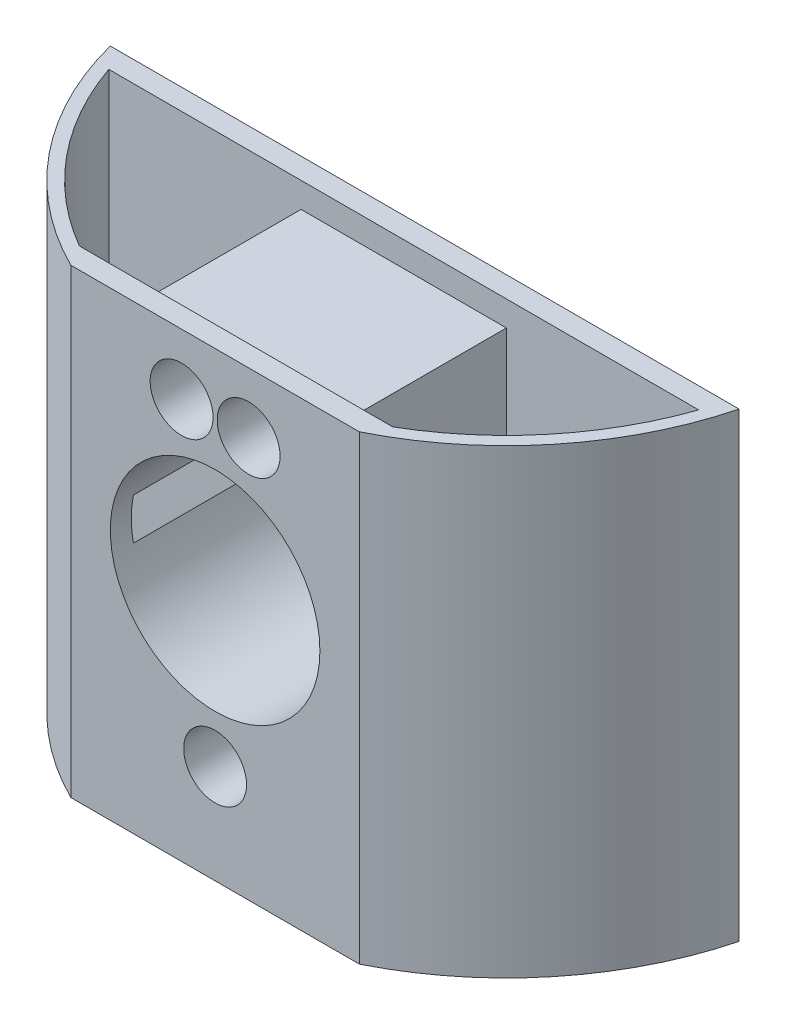
from build123d import *

# Parameters (mm, degrees)
SKETCH1_W           = 82.55
SKETCH1_H           = 76.2
BOSS_EXTRUDE1_DEPTH = 31.75
SKETCH2_R           = 4.7625
CUT_EXTRUDE1_DEPTH  = 32.75
SKETCH4_R           = 15.875
CUT_EXTRUDE3_DEPTH  = 32.75
BOSS_EXTRUDE3_DEPTH = 76.2
CUT_EXTRUDE5_DEPTH  = 77.2
CUT_EXTRUDE6_DEPTH  = 62.23
SKETCH9_W           = 31.115
SKETCH9_H           = 3.81
CUT_EXTRUDE7_DEPTH  = 25.4


with BuildPart() as part:
    # Sketch1 → Boss-Extrude1 (new body)
    with BuildSketch(Plane.XY):
        Rectangle(SKETCH1_W, SKETCH1_H)
    extrude(amount=BOSS_EXTRUDE1_DEPTH)

    # Sketch2 → Cut-Extrude1 (cut, through all)
    with BuildSketch(Plane.XY.offset(31.75)):
        with Locations((0, -23.114)):
            Circle(SKETCH2_R)
        with Locations((-5.08, 22.548849106)):
            Circle(SKETCH2_R)
        with Locations((5.08, 22.548849106)):
            Circle(SKETCH2_R)
    extrude(amount=-CUT_EXTRUDE1_DEPTH, mode=Mode.SUBTRACT)

    # Sketch4 → Cut-Extrude3 (cut, through all)
    with BuildSketch(Plane.XY.offset(31.75)):
        Circle(SKETCH4_R)
    extrude(amount=-CUT_EXTRUDE3_DEPTH, mode=Mode.SUBTRACT)

    # Sketch7 → Boss-Extrude3 (add, through all)
    with BuildSketch(Plane(origin=(0, 38.1, 0), x_dir=(1, 0, 0), z_dir=(0, 1, 0))):
        with BuildLine():
            Line((-47.639122, 0), (-41.275, 0))
            Line((-41.275, 0), (-41.275, -14.455684538))
            ThreePointArc((-41.275, -14.455684538), (-45.040781261, -7.484825392), (-47.639122, 0))
        make_face()
    boss_extrude3 = extrude(amount=-BOSS_EXTRUDE3_DEPTH)

    # Sketch6 → Cut-Extrude5 (cut, through all)
    with BuildSketch(Plane(origin=(0, 38.1, 0), x_dir=(1, 0, 0), z_dir=(0, 1, 0))):
        with BuildLine():
            Line((-41.275, -14.455684538), (-41.275, -31.75))
            Line((-41.275, -31.75), (-21.853009973, -31.75))
            ThreePointArc((-21.853009973, -31.75), (-32.727049174, -24.408972752), (-41.275, -14.455684538))
        make_face()
    cut_extrude5 = extrude(amount=-CUT_EXTRUDE5_DEPTH, mode=Mode.SUBTRACT)

    # Mirror2: Boss-Extrude3, Cut-Extrude5 across plane
    add(boss_extrude3.mirror(Plane(origin=(0, 0, 0), x_dir=(0, 0, 1), z_dir=(1, 0, 0))))
    add(cut_extrude5.mirror(Plane(origin=(0, 0, 0), x_dir=(0, 0, 1), z_dir=(1, 0, 0))), mode=Mode.SUBTRACT)


with BuildPart() as body_2:
    # Split1: the piece on the far side of the plane
    add(part.part)
    split(bisect_by=Plane(origin=(0, 31.75, 0), x_dir=(1, 0, 0), z_dir=(0, 1, 0)), keep=Keep.BOTTOM)

    # Sketch8 → Cut-Extrude6 (cut)
    with BuildSketch(Plane(origin=(0, 31.75, 0), x_dir=(1, 0, 0), z_dir=(0, 1, 0))):
        with BuildLine():
            Line((-44.689459382, -3.175), (-15.5575, -3.175))
            Line((-15.5575, -3.175), (-15.5575, -28.575))
            Line((-15.5575, -28.575), (-23.740308757, -28.575))
            ThreePointArc((-23.740308757, -28.575), (-36.495866778, -17.756285446), (-44.689459382, -3.175))
        make_face()
    cut_extrude6 = extrude(amount=-CUT_EXTRUDE6_DEPTH, mode=Mode.SUBTRACT)

    # Mirror3: Cut-Extrude6 across plane
    add(cut_extrude6.mirror(Plane(origin=(0, 0, 0), x_dir=(0, 0, 1), z_dir=(1, 0, 0))), mode=Mode.SUBTRACT)

    # Sketch9 → Cut-Extrude7 (cut)
    with BuildSketch(Plane.XY.offset(3.175)):
        with Locations((0, 29.845)):
            Rectangle(SKETCH9_W, SKETCH9_H)
    extrude(amount=CUT_EXTRUDE7_DEPTH, mode=Mode.SUBTRACT)


with BuildPart() as part_1:
    add(part.part)

    # Split1
    split(bisect_by=Plane(origin=(0, 31.75, 0), x_dir=(1, 0, 0), z_dir=(0, 1, 0)), keep=Keep.TOP)


solid = body_2.part
